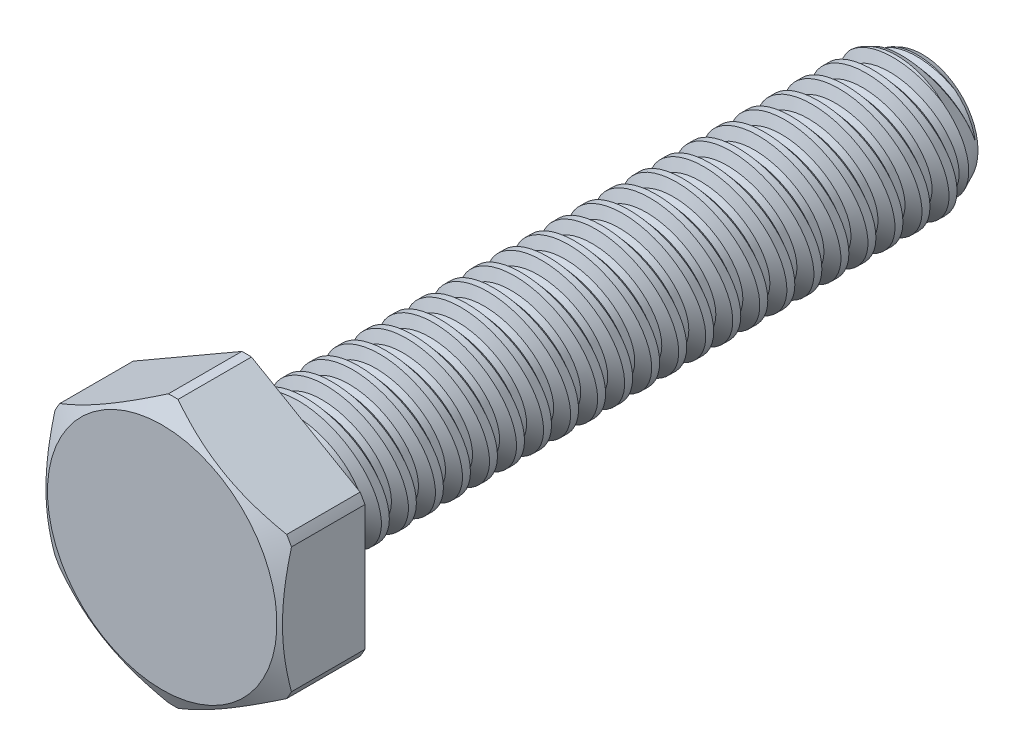
from build123d import *

# Parameters (mm, degrees)
SKETCH1_W            = 31.75
SKETCH1_H            = 3.175
LPATTERN1_COUNT      = 2
LPATTERN1_PITCH      = 1.27
LPATTERN1_COUNT_DIR2 = 25
LPATTERN1_PITCH_DIR2 = 1.27
EXTRUDE1_DEPTH       = 3.96875


with BuildPart() as part:
    # Sketch1 → Revolve1 (revolve)
    with BuildSketch(Plane(origin=(0, 0, 0), x_dir=(0, 0, -1), z_dir=(1, 0, 0)), mode=Mode.PRIVATE) as revolve1_sk:
        with Locations((0, 1.5875)):
            Rectangle(SKETCH1_W, SKETCH1_H)
    revolve(revolve1_sk.sketch.rotate(Axis((0, 0, 15.875), (0, 0, 1)), 125.380956554), axis=Axis((0, 0, 15.875), (0, 0, 1)))  # turned: the seam where the file's is

    # Sketch2 → Cut-Revolve1 (revolve, cut)
    with BuildSketch(Plane(origin=(0, 0, 0), x_dir=(0, 0, -1), z_dir=(1, 0, 0)), mode=Mode.PRIVATE) as cut_revolve1_sk:
        Polygon((-14.629662542, 3.424067492), (-15.719332818, 3.206133436), (-15.195353128, 2.609908356), (-14.884018763, 2.672175229), align=None)
    cut_revolve1 = revolve(cut_revolve1_sk.sketch.rotate(Axis((0, -0.272704483, 15.875), (0, 0.196116135, -0.980580676)), 180), axis=Axis((0, -0.272704483, 15.875), (0, 0.196116135, -0.980580676)), mode=Mode.SUBTRACT)  # turned: the seam where the file's is

    # Sketch3 → Cut-Revolve2 (revolve, cut)
    with BuildSketch(Plane(origin=(0, 0, 0), x_dir=(0, 0, -1), z_dir=(1, 0, 0)), mode=Mode.PRIVATE) as cut_revolve2_sk:
        Polygon((14.663157058, 3.175), (15.875, 2.609908356), (15.875, 3.175), align=None)
    revolve(cut_revolve2_sk.sketch.rotate(Axis((0, 0, 0), (0, 0, -1)), 234.619043446), axis=Axis((0, 0, 0), (0, 0, -1)), mode=Mode.SUBTRACT)  # turned: the seam where the file's is

    # LPattern1: Cut-Revolve1 2 × 25
    with Locations(*[Vector(0, 0, 1) * (i * LPATTERN1_PITCH) + Vector(0, 0, -1) * (j * LPATTERN1_PITCH_DIR2) for i in range(LPATTERN1_COUNT) for j in range(LPATTERN1_COUNT_DIR2) if (i, j) != (0, 0)]):
        add(cut_revolve1, mode=Mode.SUBTRACT)

    # Sketch5 → Extrude1 (add)
    with BuildSketch(Plane.XY.offset(15.875)):
        Polygon((0, 6.415804866), (-5.55625, 3.207902433), (-5.55625, -3.207902433), (0, -6.415804866), (5.55625, -3.207902433), (5.55625, 3.207902433), align=None)
    extrude(amount=EXTRUDE1_DEPTH)

    # Sketch6 → Cut-Revolve3 (revolve, cut)
    with BuildSketch(Plane(origin=(0, 0, 0), x_dir=(0, 0, -1), z_dir=(1, 0, 0)), mode=Mode.PRIVATE) as cut_revolve3_sk:
        Polygon((-19.84375, 5.3895625), (-19.324572178, 6.288804866), (-15.875, 6.288804866), (-15.875, 6.796804866), (-19.84375, 6.796804866), align=None)
    revolve(cut_revolve3_sk.sketch.rotate(Axis((0, 0, 0), (0, 0, 1)), 125.380956554), axis=Axis((0, 0, 0), (0, 0, 1)), mode=Mode.SUBTRACT)  # turned: the seam where the file's is


solid = part.part
